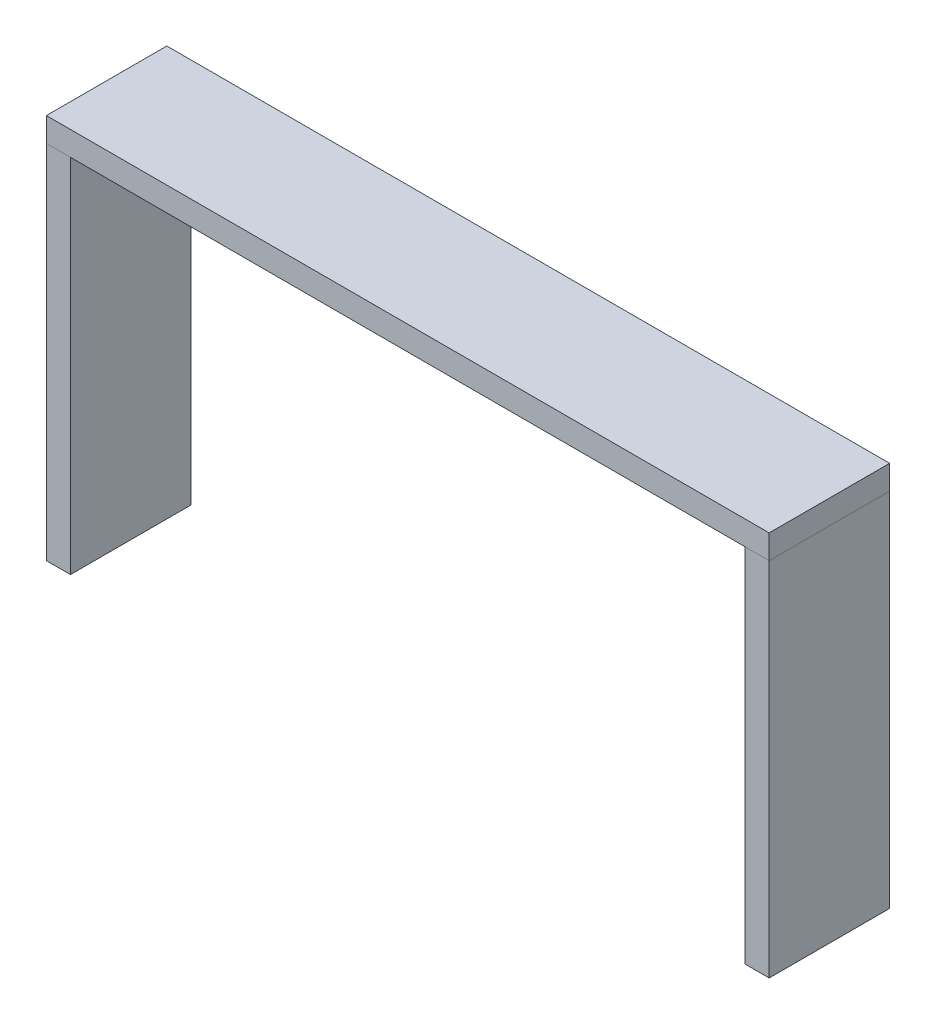
from build123d import *

# Parameters (mm, degrees)
SKETCH1_W             = 20
SKETCH1_H             = 100
BOSS_EXTRUDE1_DEPTH   = 300
BOSS_EXTRUDE1_2_DEPTH = 300
SKETCH2_W             = 600
SKETCH2_H             = 100
BOSS_EXTRUDE2_DEPTH   = 20


with BuildPart() as part:
    # Sketch1 → Boss-Extrude1 (new body)
    with BuildSketch(Plane(origin=(0, 0, 0), x_dir=(1, 0, 0), z_dir=(0, 1, 0))):
        with Locations((-290, 0)):
            Rectangle(SKETCH1_W, SKETCH1_H)
    extrude(amount=BOSS_EXTRUDE1_DEPTH)


with BuildPart() as body_2:
    # Sketch1 → Boss-Extrude1 2 (new body)
    with BuildSketch(Plane(origin=(0, 0, 0), x_dir=(1, 0, 0), z_dir=(0, 1, 0))):
        with Locations((290, 0)):
            Rectangle(SKETCH1_W, SKETCH1_H)
    extrude(amount=BOSS_EXTRUDE1_2_DEPTH)


with BuildPart() as body_3:
    # Sketch2 → Boss-Extrude2 (new body)
    with BuildSketch(Plane(origin=(0, 300, 0), x_dir=(1, 0, 0), z_dir=(0, 1, 0))):
        Rectangle(SKETCH2_W, SKETCH2_H)
    extrude(amount=BOSS_EXTRUDE2_DEPTH)


solid = Compound([part.part, body_2.part, body_3.part])
